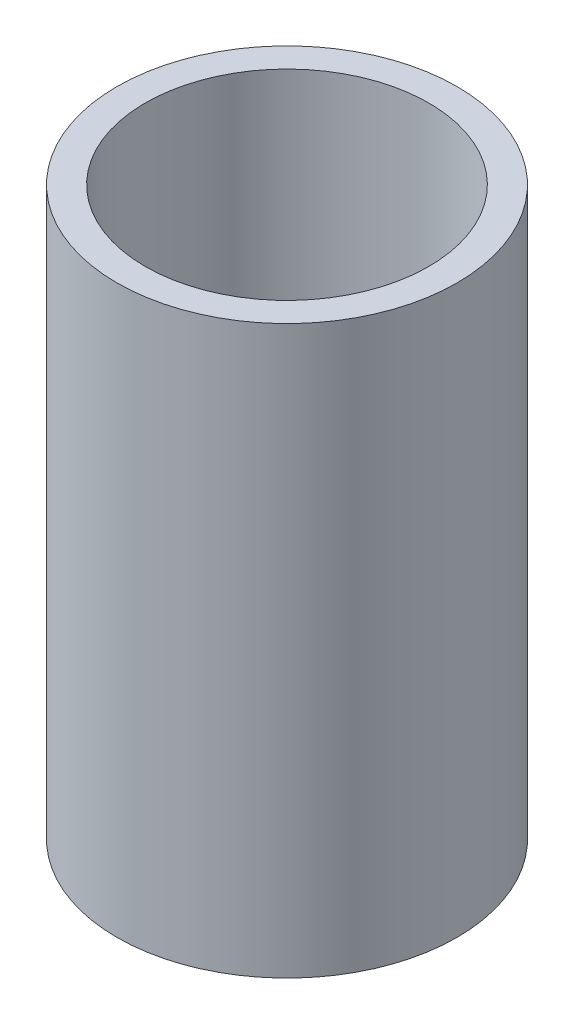
from build123d import *

# Parameters (mm, degrees)
SKETCH1_R           = 4.7625
SKETCH1_R_2         = 3.96875
BOSS_EXTRUDE1_DEPTH = 15.875


with BuildPart() as part:
    # Sketch1 → Boss-Extrude1 (new body)
    with BuildSketch(Plane(origin=(0, 0, 0), x_dir=(1, 0, 0), z_dir=(0, 1, 0))):
        Circle(SKETCH1_R)
        Circle(SKETCH1_R_2, mode=Mode.SUBTRACT)
    extrude(amount=BOSS_EXTRUDE1_DEPTH)


solid = part.part
